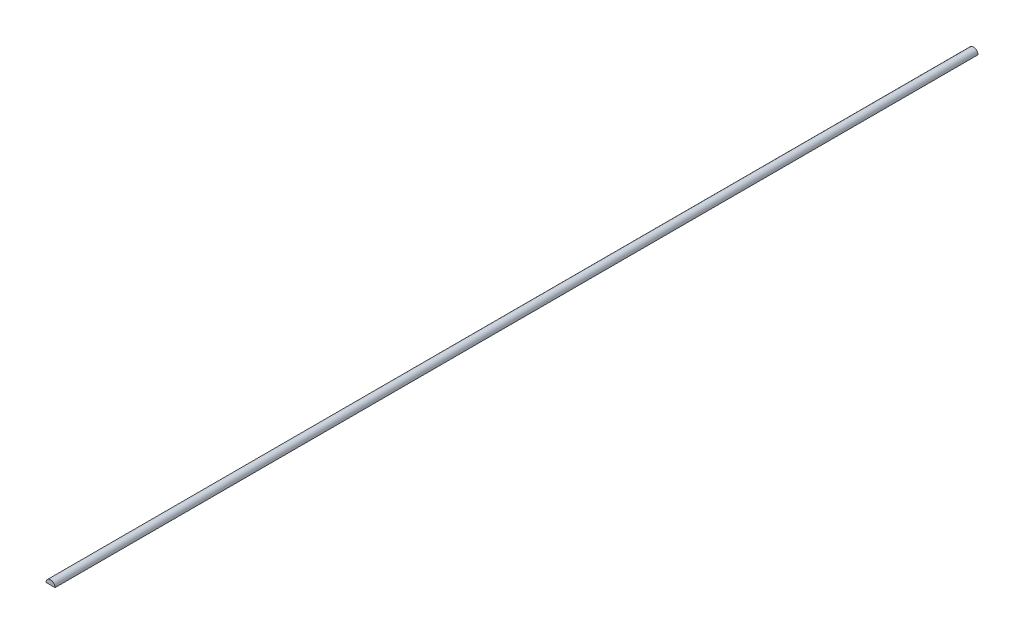
from build123d import *

# Parameters (mm, degrees)
EXTRUDE1_DEPTH = 101.95


with BuildPart() as part:
    # Sketch1 → Extrude1 (new body, symmetric)
    with BuildSketch(Plane.XY):
        with BuildLine():
            Line((-1, 0), (1, 0))
            ThreePointArc((1, 0), (0, 1), (-1, 0))
        make_face()
    extrude(amount=EXTRUDE1_DEPTH, both=True)


solid = part.part
